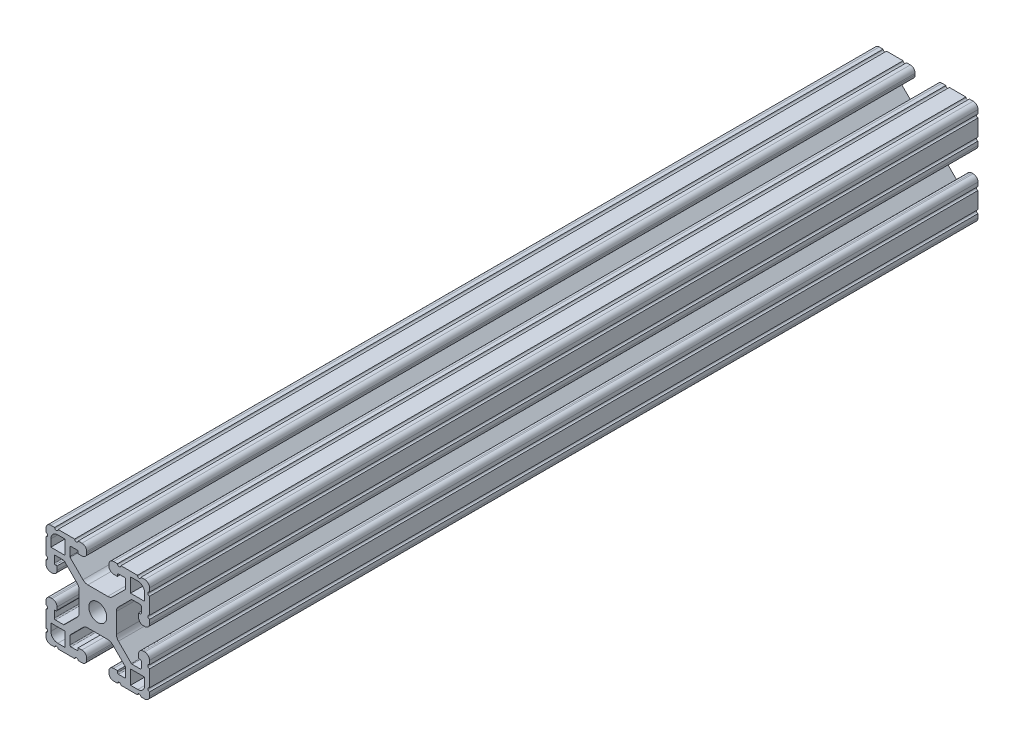
from build123d import *

# Parameters (mm, degrees)
SKETCH3_W                = 38.1
SKETCH3_H                = 38.1
BOSS_EXTRUDE1_DEPTH      = 152.4
BOSS_EXTRUDE1_DEPTH_BACK = 152.4
SKETCH4_W                = 5.207
SKETCH4_H                = 5.207
SKETCH4_R                = 3.302
CUT_EXTRUDE1_DEPTH       = 305.8
CUT_EXTRUDE2_DEPTH       = 305.8
FILLET1_R                = 2.54
FILLET2_R                = 1.778
FILLET3_R                = 0.396875


with BuildPart() as part:
    # Sketch3 → Boss-Extrude1 (new body, two sides)
    with BuildSketch(Plane.XY) as boss_extrude1_sk:
        Rectangle(SKETCH3_W, SKETCH3_H)
    extrude(amount=BOSS_EXTRUDE1_DEPTH)
    extrude(boss_extrude1_sk.sketch, amount=-BOSS_EXTRUDE1_DEPTH_BACK)

    # Sketch4 → Cut-Extrude1 (cut, through all)
    with BuildSketch(Plane.XY.offset(152.4)):
        Polygon((7.239, 14.986), (4.064, 14.986), (4.064, 19.05), (-4.064, 19.05), (-4.064, 14.986), (-7.239, 14.986), (-7.239, 16.002), (-10.287, 16.002), (-10.287, 12.442261469), (-4.702738531, 6.858), (4.702738531, 6.858), (10.287, 12.442261469), (10.287, 16.002), (7.239, 16.002), align=None)
        Polygon((10.287, -12.442261469), (4.702738531, -6.858), (-4.702738531, -6.858), (-10.287, -12.442261469), (-10.287, -16.002), (-7.239, -16.002), (-7.239, -14.986), (-4.064, -14.986), (-4.064, -19.05), (4.064, -19.05), (4.064, -14.986), (7.239, -14.986), (7.239, -16.002), (10.287, -16.002), align=None)
        Polygon((-12.442261469, -10.287), (-6.858, -4.702738531), (-6.858, 4.702738531), (-12.442261469, 10.287), (-16.002, 10.287), (-16.002, 7.239), (-14.986, 7.239), (-14.986, 4.064), (-19.05, 4.064), (-19.05, -4.064), (-14.986, -4.064), (-14.986, -7.239), (-16.002, -7.239), (-16.002, -10.287), align=None)
        Polygon((14.986, -7.239), (14.986, -4.064), (19.05, -4.064), (19.05, 4.064), (14.986, 4.064), (14.986, 7.239), (16.002, 7.239), (16.002, 10.287), (12.442261469, 10.287), (6.858, 4.702738531), (6.858, -4.702738531), (12.442261469, -10.287), (16.002, -10.287), (16.002, -7.239), align=None)
        with Locations((14.6685, 14.6685)):
            Rectangle(SKETCH4_W, SKETCH4_H)
        with Locations((14.6685, -14.6685)):
            Rectangle(SKETCH4_W, SKETCH4_H)
        with Locations((-14.6685, 14.6685)):
            Rectangle(SKETCH4_W, SKETCH4_H)
        with Locations((-14.6685, -14.6685)):
            Rectangle(SKETCH4_W, SKETCH4_H)
        Circle(SKETCH4_R)
    extrude(amount=-CUT_EXTRUDE1_DEPTH, mode=Mode.SUBTRACT)

    # Sketch5 → Cut-Extrude2 (cut, through all)
    with BuildSketch(Plane.XY.offset(152.4)):
        with BuildLine():
            Line((-14.605, 19.05), (-15.875, 19.05))
            ThreePointArc((-15.875, 19.05), (-15.24, 18.415), (-14.605, 19.05))
        make_face()
        with BuildLine():
            Line((-7.239, 19.05), (-8.509, 19.05))
            ThreePointArc((-8.509, 19.05), (-7.874, 18.415), (-7.239, 19.05))
        make_face()
        with BuildLine():
            ThreePointArc((-19.05, 14.605), (-18.415, 15.24), (-19.05, 15.875))
            Line((-19.05, 15.875), (-19.05, 14.605))
        make_face()
        with BuildLine():
            ThreePointArc((-19.05, 7.239), (-18.415, 7.874), (-19.05, 8.509))
            Line((-19.05, 8.509), (-19.05, 7.239))
        make_face()
        with BuildLine():
            ThreePointArc((7.239, 19.05), (7.874, 18.415), (8.509, 19.05))
            Line((8.509, 19.05), (7.239, 19.05))
        make_face()
        with BuildLine():
            ThreePointArc((14.605, 19.05), (15.24, 18.415), (15.875, 19.05))
            Line((15.875, 19.05), (14.605, 19.05))
        make_face()
        with BuildLine():
            Line((19.05, 14.605), (19.05, 15.875))
            ThreePointArc((19.05, 15.875), (18.415, 15.24), (19.05, 14.605))
        make_face()
        with BuildLine():
            Line((19.05, 7.239), (19.05, 8.509))
            ThreePointArc((19.05, 8.509), (18.415, 7.874), (19.05, 7.239))
        make_face()
        with BuildLine():
            ThreePointArc((19.05, -7.239), (18.415, -7.874), (19.05, -8.509))
            Line((19.05, -8.509), (19.05, -7.239))
        make_face()
        with BuildLine():
            ThreePointArc((19.05, -14.605), (18.415, -15.24), (19.05, -15.875))
            Line((19.05, -15.875), (19.05, -14.605))
        make_face()
        with BuildLine():
            Line((14.605, -19.05), (15.875, -19.05))
            ThreePointArc((15.875, -19.05), (15.24, -18.415), (14.605, -19.05))
        make_face()
        with BuildLine():
            Line((7.239, -19.05), (8.509, -19.05))
            ThreePointArc((8.509, -19.05), (7.874, -18.415), (7.239, -19.05))
        make_face()
        with BuildLine():
            ThreePointArc((-7.239, -19.05), (-7.874, -18.415), (-8.509, -19.05))
            Line((-8.509, -19.05), (-7.239, -19.05))
        make_face()
        with BuildLine():
            ThreePointArc((-14.605, -19.05), (-15.24, -18.415), (-15.875, -19.05))
            Line((-15.875, -19.05), (-14.605, -19.05))
        make_face()
        with BuildLine():
            Line((-19.05, -14.605), (-19.05, -15.875))
            ThreePointArc((-19.05, -15.875), (-18.415, -15.24), (-19.05, -14.605))
        make_face()
        with BuildLine():
            Line((-19.05, -7.239), (-19.05, -8.509))
            ThreePointArc((-19.05, -8.509), (-18.415, -7.874), (-19.05, -7.239))
        make_face()
    extrude(amount=-CUT_EXTRUDE2_DEPTH, mode=Mode.SUBTRACT)

    # Fillet1
    fillet1_edges = [part.edges().sort_by_distance(p)[0] for p in [
        (6.858, -4.702738531, 0),
        (6.858, 4.702738531, 0),
        (-17.272, 17.272, 0),
        (-17.272, -17.272, 0),
        (17.272, -17.272, 0),
        (17.272, 17.272, 0),
        (-4.702738531, -6.858, 0),
        (4.702738531, -6.858, 0),
        (-6.858, 4.702738531, 0),
        (-6.858, -4.702738531, 0),
        (4.702738531, 6.858, 0),
        (-4.702738531, 6.858, 0),
    ]]
    fillet(fillet1_edges, radius=FILLET1_R)

    # Fillet2
    fillet2_edges = [part.edges().sort_by_distance(p)[0] for p in [
        (14.986, 4.064, 0),
        (19.05, 4.064, 0),
        (19.05, -4.064, 0),
        (14.986, -4.064, 0),
        (4.064, -14.986, 0),
        (4.064, -19.05, 0),
        (-4.064, -19.05, 0),
        (-4.064, -14.986, 0),
        (-14.986, -4.064, 0),
        (-19.05, -4.064, 0),
        (-19.05, 4.064, 0),
        (-14.986, 4.064, 0),
        (-19.05, 19.05, 0),
        (19.05, 19.05, 0),
        (19.05, -19.05, 0),
        (-19.05, -19.05, 0),
        (-4.064, 14.986, 0),
        (-4.064, 19.05, 0),
        (4.064, 19.05, 0),
        (4.064, 14.986, 0),
    ]]
    fillet(fillet2_edges, radius=FILLET2_R)

    # Fillet3
    fillet3_edges = [part.edges().sort_by_distance(p)[0] for p in [
        (12.442261469, 10.287, 0),
        (16.002, 10.287, 0),
        (16.002, 7.239, 0),
        (16.002, -7.239, 0),
        (16.002, -10.287, 0),
        (12.442261469, -10.287, 0),
        (-7.239, -16.002, 0),
        (-10.287, -16.002, 0),
        (-10.287, -12.442261469, 0),
        (10.287, -12.442261469, 0),
        (10.287, -16.002, 0),
        (7.239, -16.002, 0),
        (-16.002, 7.239, 0),
        (-16.002, 10.287, 0),
        (-12.442261469, 10.287, 0),
        (-12.442261469, -10.287, 0),
        (-16.002, -10.287, 0),
        (-14.986, -7.239, 0),
        (-10.287, 12.442261469, 0),
        (-10.287, 16.002, 0),
        (-7.239, 16.002, 0),
        (7.239, 16.002, 0),
        (10.287, 16.002, 0),
        (10.287, 12.442261469, 0),
    ]]
    fillet(fillet3_edges, radius=FILLET3_R)


solid = part.part
